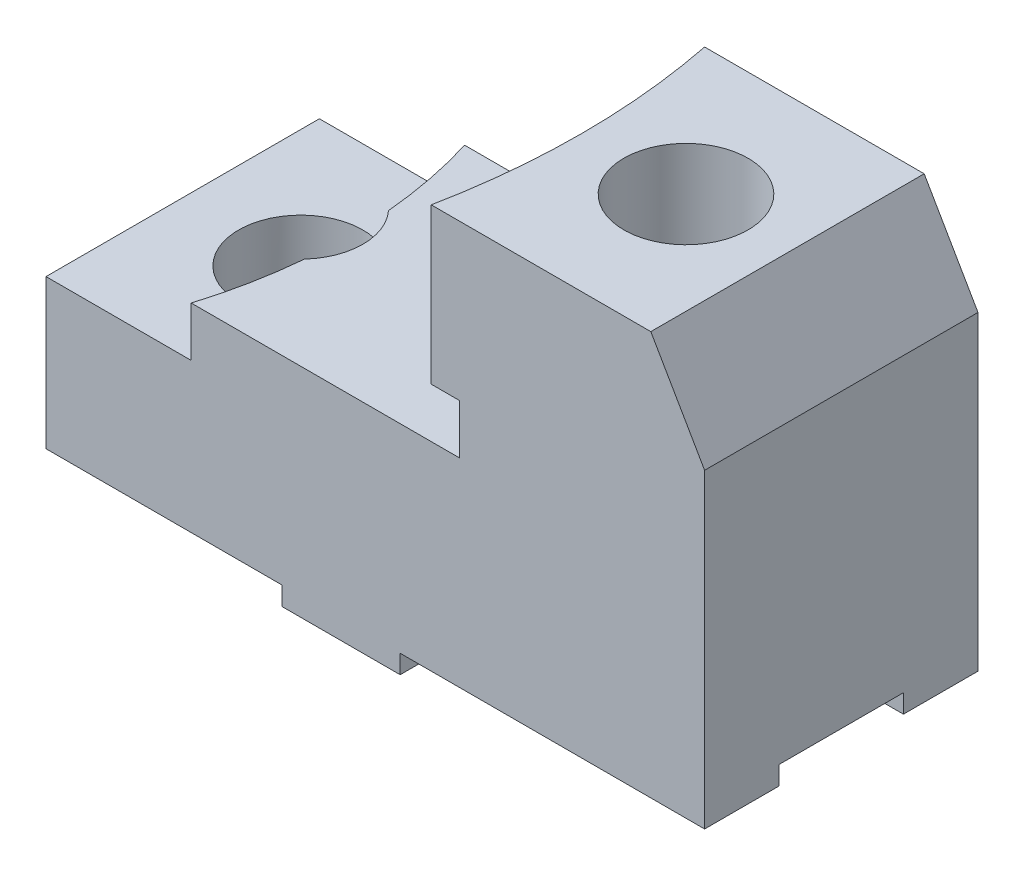
from build123d import *

# Parameters (mm, degrees)
BASE_DEPTH         = 44
MIDDLE_LEVEL_DEPTH = 8
UP_LEVEL_DEPTH     = 41
ANGLE_START        = 41
ANGLE_LEVEL_DEPTH  = 25
BIG_START          = 8
SKETCH2_7_R        = 6.5
BIG_CYL_DEPTH      = 22
SKETCH2_8_R        = 6.5
SMALL_CYL_DEPTH    = 28
SKETCH5_R          = 10
SKETCH5_R_2        = 6.5
BIG_CYL_2_DEPTH    = 22
SKETCH5_2_R        = 6.5
SMALL_CYL_2_DEPTH  = 69
BASE_ANGLE_DEPTH   = 45
SKETCH7_W          = 20
SKETCH7_H          = 6
DOWN_CUT_DEPTH     = 107


with BuildPart() as part:
    # Sketch1 → base (new body)
    with BuildSketch(Plane.XY):
        Polygon((-47.5, -12), (-47.5, 12), (58.5, 12), (58.5, -12), (9.5, -12), (9.5, -15), (-9.5, -15), (-9.5, -12), align=None)
    extrude(amount=-BASE_DEPTH)

    # Sketch2_4 → middle level (add)
    with BuildSketch(Plane(origin=(0, 12, 0), x_dir=(1, 0, 0), z_dir=(0, 1, 0))):
        with BuildLine():
            Line((14.5, 44), (-24.127153, 44))
            ThreePointArc((-24.127153, 44), (-22.234873, 36.459024), (-21.133434, 28.76267))
            ThreePointArc((-21.133434, 28.76267), (-19.181586, 25.628659), (-18.5, 22))
            ThreePointArc((-18.5, 22), (-19.181586, 18.371341), (-21.133434, 15.23733))
            ThreePointArc((-21.133434, 15.23733), (-22.234873, 7.540976), (-24.127153, 0))
            Line((-24.127153, 0), (14.5, 0))
            ThreePointArc((14.5, 0), (16.67208, 22), (14.5, 44))
        make_face()
        with BuildLine():
            Line((19.08509, 44), (14.5, 44))
            ThreePointArc((14.5, 44), (16.67208, 22), (14.5, 0))
            Line((14.5, 0), (19.08509, 0))
            ThreePointArc((19.08509, 0), (21.17208, 22), (19.08509, 44))
        make_face()
    extrude(amount=MIDDLE_LEVEL_DEPTH)

    # Sketch2 → up level (add)
    with BuildSketch(Plane(origin=(0, 12, 0), x_dir=(1, 0, 0), z_dir=(0, 1, 0))):
        with BuildLine():
            Line((58.5, 44), (19.08509, 44))
            ThreePointArc((19.08509, 44), (21.17208, 22), (19.08509, 0))
            Line((19.08509, 0), (58.5, 0))
            Line((58.5, 0), (58.5, 44))
        make_face()
    extrude(amount=UP_LEVEL_DEPTH)

    # Sketch2_6 → angle level (add)
    with BuildSketch(Plane(origin=(0, 12, 0), x_dir=(1, 0, 0), z_dir=(0, 1, 0)).offset(ANGLE_START)):
        with BuildLine():
            Line((19.08509, 44), (14.5, 44))
            ThreePointArc((14.5, 44), (16.67208, 22), (14.5, 0))
            Line((14.5, 0), (19.08509, 0))
            ThreePointArc((19.08509, 0), (21.17208, 22), (19.08509, 44))
        make_face()
    extrude(amount=-ANGLE_LEVEL_DEPTH)

    # Sketch2_7 → big cyl (cut)
    with BuildSketch(Plane(origin=(0, 12, 0), x_dir=(1, 0, 0), z_dir=(0, 1, 0)).offset(BIG_START)):
        with BuildLine():
            ThreePointArc((-18.5, 22), (-19.181586, 25.628659), (-21.133434, 28.76267))
            ThreePointArc((-21.133434, 28.76267), (-20.82792, 22), (-21.133434, 15.23733))
            ThreePointArc((-21.133434, 15.23733), (-19.181586, 18.371341), (-18.5, 22))
        make_face()
        with BuildLine():
            ThreePointArc((-21.133434, 15.23733), (-20.82792, 22), (-21.133434, 28.76267))
            ThreePointArc((-21.133434, 28.76267), (-38.5, 22), (-21.133434, 15.23733))
        make_face()
        with Locations((-28.5, 22)):
            Circle(SKETCH2_7_R, mode=Mode.SUBTRACT)
    extrude(amount=-BIG_CYL_DEPTH, mode=Mode.SUBTRACT)

    # Sketch2_8 → small cyl (cut, through all)
    with BuildSketch(Plane(origin=(0, 12, 0), x_dir=(1, 0, 0), z_dir=(0, 1, 0))):
        with Locations((-28.5, 22)):
            Circle(SKETCH2_8_R)
    extrude(amount=-SMALL_CYL_DEPTH, mode=Mode.SUBTRACT)

    # Sketch5 → big cyl 2 (cut)
    with BuildSketch(Plane(origin=(0, 53, 0), x_dir=(1, 0, 0), z_dir=(0, 1, 0))):
        with Locations((33.5, 22)):
            Circle(SKETCH5_R)
        with Locations((33.5, 22)):
            Circle(SKETCH5_R_2, mode=Mode.SUBTRACT)
    extrude(amount=-BIG_CYL_2_DEPTH, mode=Mode.SUBTRACT)

    # Sketch5_2 → small cyl 2 (cut, through all)
    with BuildSketch(Plane(origin=(0, 53, 0), x_dir=(1, 0, 0), z_dir=(0, 1, 0))):
        with Locations((33.5, 22)):
            Circle(SKETCH5_2_R)
    extrude(amount=-SMALL_CYL_2_DEPTH, mode=Mode.SUBTRACT)

    # Sketch6 → base angle (cut, through all)
    with BuildSketch(Plane.XY):
        Polygon((49.839746, 53), (58.5, 38), (58.5, 53), align=None)
    extrude(amount=-BASE_ANGLE_DEPTH, mode=Mode.SUBTRACT)

    # Sketch7 → down cut (cut, through all)
    with BuildSketch(Plane.ZY.offset(47.5)):
        with Locations((-22, -12)):
            Rectangle(SKETCH7_W, SKETCH7_H)
    extrude(amount=-DOWN_CUT_DEPTH, mode=Mode.SUBTRACT)


solid = part.part
